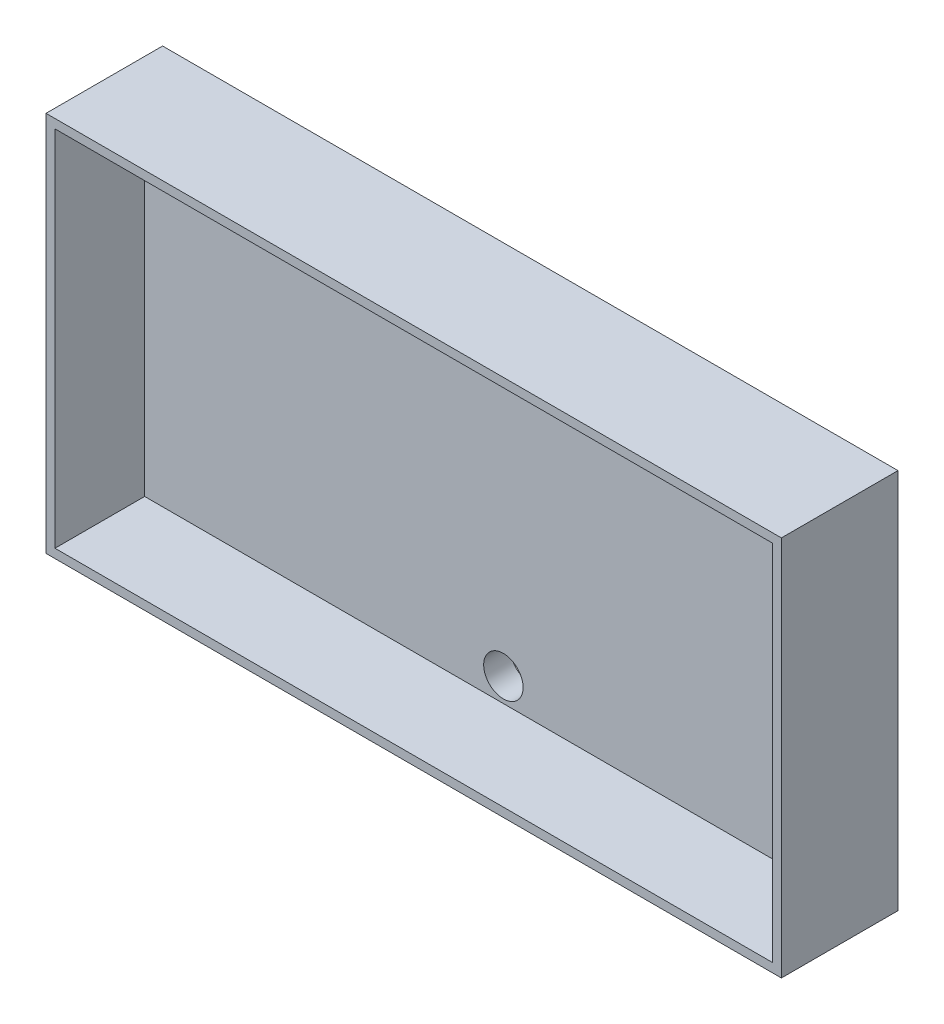
from build123d import *

# Parameters (mm, degrees)
SKETCH1_W                   = 82
SKETCH1_H                   = 42.5
SKETCH1_W_2                 = 80
SKETCH1_H_2                 = 40.5
VYSUNOUT_TENKOST_NN_1_DEPTH = 10
SKICA1_W                    = 82
SKICA1_H                    = 42.5
P_IDAT_VYSUNUT_M1_DEPTH     = 3
SKETCH3_R                   = 2.2
CUT_EXTRUDE2_DEPTH          = 11
CUT_EXTRUDE2_DEPTH_BACK     = 4


with BuildPart() as part:
    # Sketch1 → Vysunout tenkostěnný1 (new body)
    with BuildSketch(Plane.XY):
        Rectangle(SKETCH1_W, SKETCH1_H)
        Rectangle(SKETCH1_W_2, SKETCH1_H_2, mode=Mode.SUBTRACT)
    extrude(amount=VYSUNOUT_TENKOST_NN_1_DEPTH)

    # Skica1 → Přidat vysunutím1 (add)
    with BuildSketch(Plane.XY):
        Rectangle(SKICA1_W, SKICA1_H)
    extrude(amount=-P_IDAT_VYSUNUT_M1_DEPTH)

    # Sketch3 → Cut-Extrude2 (cut, two sides)
    with BuildSketch(Plane.XY) as cut_extrude2_sk:
        with Locations((0, -17.6)):
            Circle(SKETCH3_R)
        with Locations((0, 17.6)):
            Circle(SKETCH3_R)
    extrude(amount=CUT_EXTRUDE2_DEPTH, mode=Mode.SUBTRACT)
    extrude(cut_extrude2_sk.sketch, amount=-CUT_EXTRUDE2_DEPTH_BACK, mode=Mode.SUBTRACT)


solid = part.part
